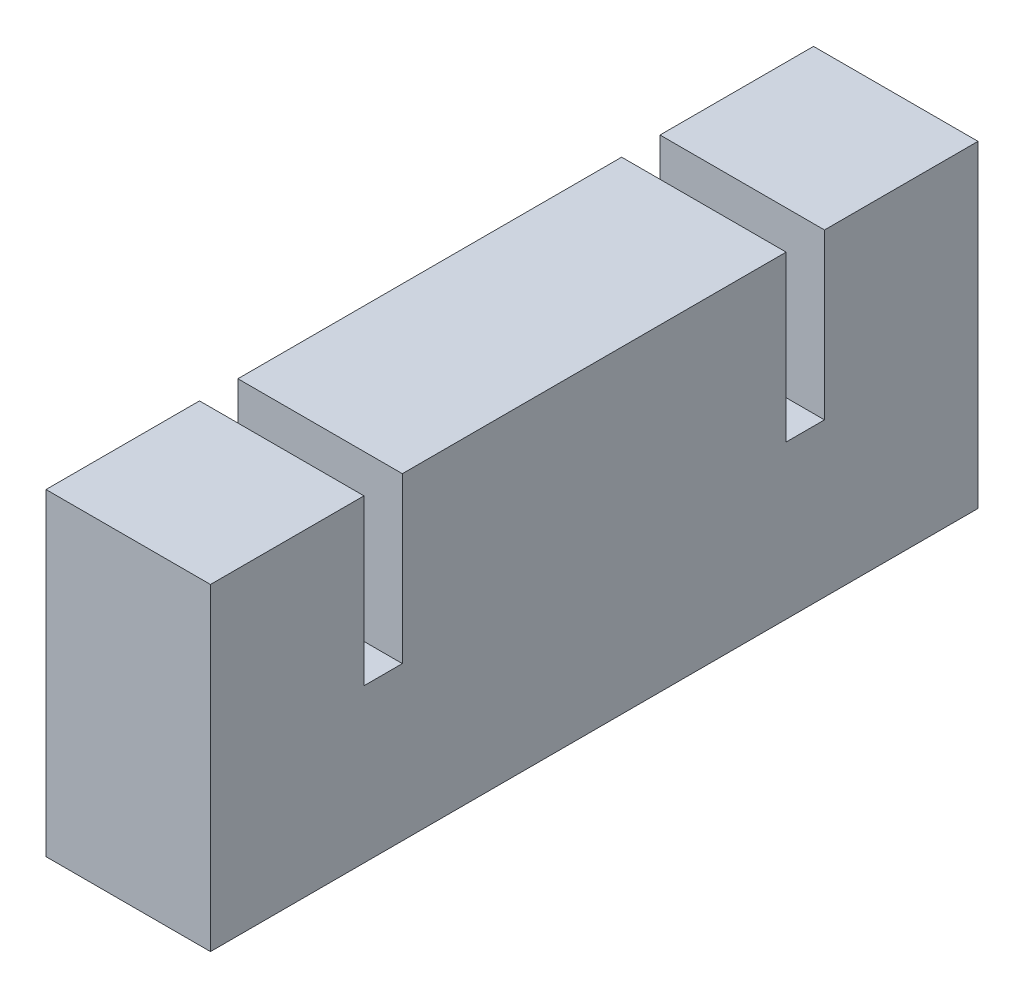
from build123d import *

# Parameters (mm, degrees)
SKETCH1_W           = 15
SKETCH1_H           = 70
BOSS_EXTRUDE1_DEPTH = 14
SKETCH2_W           = 15
SKETCH2_H           = 35
SKETCH2_H_2         = 14
BOSS_EXTRUDE2_DEPTH = 15


with BuildPart() as part:
    # Sketch1 → Boss-Extrude1 (new body)
    with BuildSketch(Plane(origin=(0, 0, 0), x_dir=(1, 0, 0), z_dir=(0, 1, 0))):
        with Locations((7.5, 35)):
            Rectangle(SKETCH1_W, SKETCH1_H)
    extrude(amount=BOSS_EXTRUDE1_DEPTH)

    # Sketch2 → Boss-Extrude2 (add)
    with BuildSketch(Plane(origin=(0, 14, 0), x_dir=(1, 0, 0), z_dir=(0, 1, 0))):
        with Locations((7.5, 35)):
            Rectangle(SKETCH2_W, SKETCH2_H)
        with Locations((7.5, 7)):
            Rectangle(SKETCH2_W, SKETCH2_H_2)
        with Locations((7.5, 63)):
            Rectangle(SKETCH2_W, SKETCH2_H_2)
    extrude(amount=BOSS_EXTRUDE2_DEPTH)


solid = part.part
